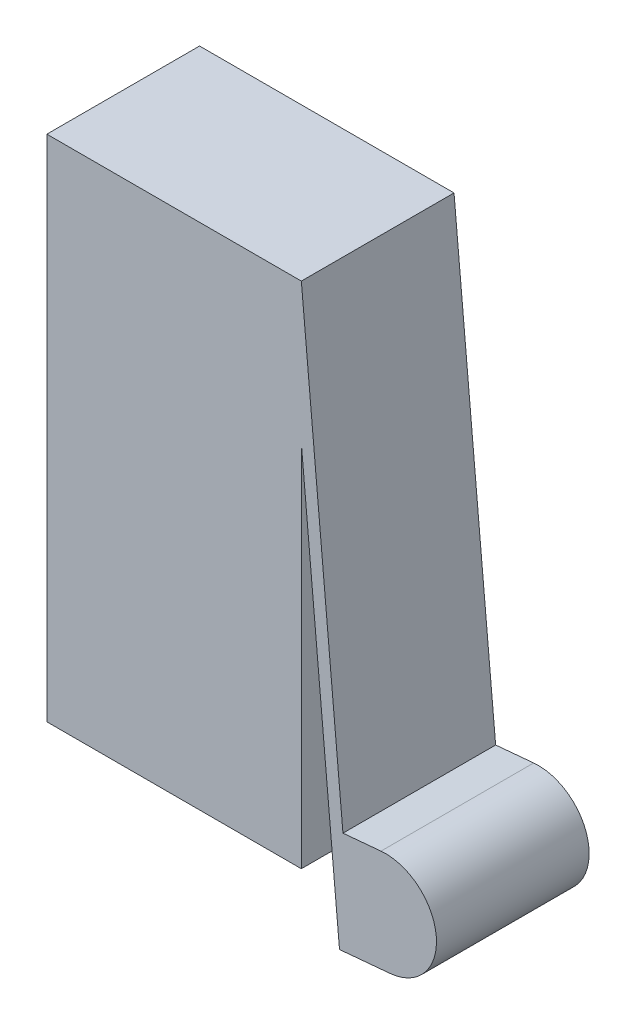
from build123d import *

# Parameters (mm, degrees)
SZKIC1_W                    = 10
SZKIC1_H                    = 20
DODANIE_WYCI_GNI_CIE1_DEPTH = 6


with BuildPart() as part:
    # Szkic1 → Dodanie-wyciągnięcie1 (new body)
    with BuildSketch(Plane.XY):
        with Locations((5, 10)):
            Rectangle(SZKIC1_W, SZKIC1_H)
        with BuildLine():
            Line((10, 20), (10, 14.482972118))
            Line((10, 14.482972118), (11.5, -2))
            Line((11.5, -2), (13.491769539, -1.818742986))
            ThreePointArc((13.491769539, -1.818742986), (15.302282063, 0.354283567), (13.129255511, 2.164796091))
            Line((13.129255511, 2.164796091), (11.635428357, 2.028853331))
            Line((11.635428357, 2.028853331), (10, 20))
        make_face()
    extrude(amount=DODANIE_WYCI_GNI_CIE1_DEPTH)


solid = part.part
